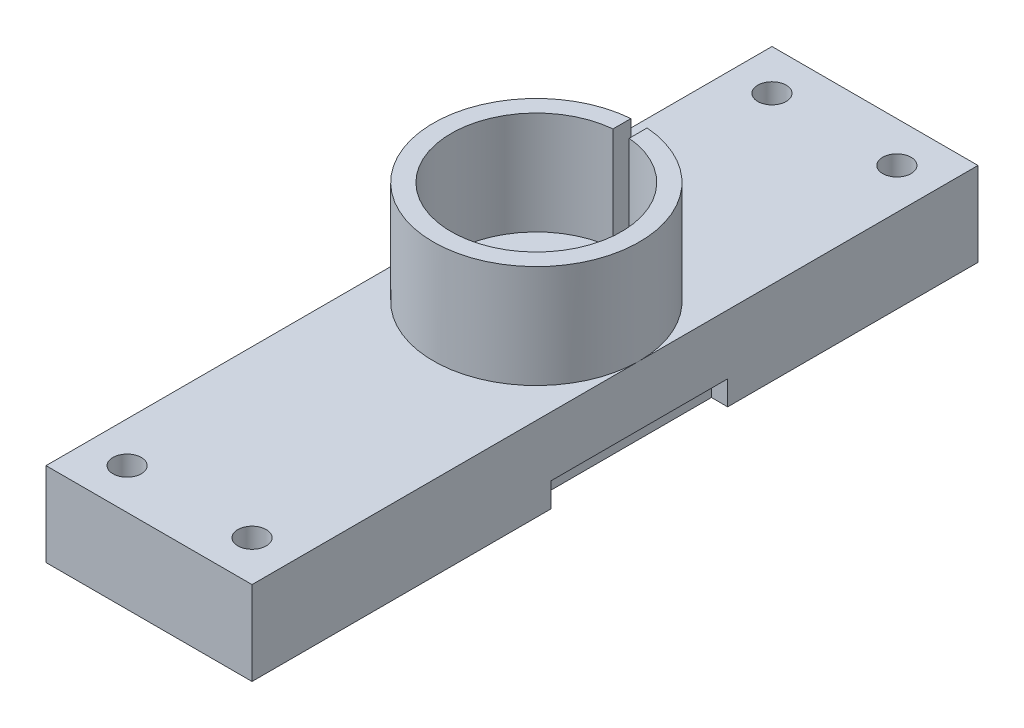
from build123d import *

# Parameters (mm, degrees)
SKETCH1_W           = 25.4
SKETCH1_H           = 89.50000007
SKETCH1_R           = 1.75
BOSS_EXTRUDE1_DEPTH = 10.35
SKETCH2_R           = 12.7
SKETCH2_R_2         = 10.5
BOSS_EXTRUDE2_DEPTH = 12.7
SKETCH5_W           = 2
SKETCH5_H           = 8.007473722
CUT_EXTRUDE1_DEPTH  = 12.7
SKETCH6_R           = 6
CUT_EXTRUDE2_DEPTH  = 3
SKETCH7_R           = 2
CUT_EXTRUDE3_DEPTH  = 7.35
SKETCH8_W           = 21.78000007
SKETCH8_H           = 3
CUT_EXTRUDE4_DEPTH  = 2


with BuildPart() as part:
    # Sketch1 → Boss-Extrude1 (new body)
    with BuildSketch(Plane(origin=(0, 0, 0), x_dir=(1, 0, 0), z_dir=(0, 1, 0))):
        with Locations((12.7, 44.750000035)):
            Rectangle(SKETCH1_W, SKETCH1_H)
        with Locations((5, 84.50000007)):
            Circle(SKETCH1_R, mode=Mode.SUBTRACT)
        with Locations((20.4, 84.50000007)):
            Circle(SKETCH1_R, mode=Mode.SUBTRACT)
        with Locations((5, 5)):
            Circle(SKETCH1_R, mode=Mode.SUBTRACT)
        with Locations((20.4, 5)):
            Circle(SKETCH1_R, mode=Mode.SUBTRACT)
    extrude(amount=BOSS_EXTRUDE1_DEPTH)

    # Sketch2 → Boss-Extrude2 (add)
    with BuildSketch(Plane(origin=(0, 10.35, 0), x_dir=(1, 0, 0), z_dir=(0, 1, 0))):
        with Locations((12.7, 47.75000007)):
            Circle(SKETCH2_R)
        with Locations((12.7, 47.75000007)):
            Circle(SKETCH2_R_2, mode=Mode.SUBTRACT)
    extrude(amount=BOSS_EXTRUDE2_DEPTH)

    # Sketch5 → Cut-Extrude1 (cut)
    with BuildSketch(Plane(origin=(0, 23.05, 0), x_dir=(1, 0, 0), z_dir=(0, 1, 0))):
        with Locations((12.7, 58.700520661)):
            Rectangle(SKETCH5_W, SKETCH5_H)
    extrude(amount=-CUT_EXTRUDE1_DEPTH, mode=Mode.SUBTRACT)

    # Sketch6 → Cut-Extrude2 (cut)
    with BuildSketch(Plane(origin=(0, 10.35, 0), x_dir=(1, 0, 0), z_dir=(0, 1, 0))):
        with Locations((12.7, 47.75000007)):
            Circle(SKETCH6_R)
    extrude(amount=-CUT_EXTRUDE2_DEPTH, mode=Mode.SUBTRACT)

    # Sketch7 → Cut-Extrude3 (cut)
    with BuildSketch(Plane(origin=(0, 7.35, 0), x_dir=(1, 0, 0), z_dir=(0, 1, 0))):
        with Locations((12.7, 47.75000007)):
            Circle(SKETCH7_R)
    extrude(amount=-CUT_EXTRUDE3_DEPTH, mode=Mode.SUBTRACT)

    # Sketch8 → Cut-Extrude4 (cut)
    with BuildSketch(Plane(origin=(25.4, 0, 0), x_dir=(0, 0, -1), z_dir=(1, 0, 0))):
        with Locations((47.750000035, 1.5)):
            Rectangle(SKETCH8_W, SKETCH8_H)
    cut_extrude4 = extrude(amount=-CUT_EXTRUDE4_DEPTH, mode=Mode.SUBTRACT)

    # Mirror1: Cut-Extrude4 across plane
    add(cut_extrude4.mirror(Plane.ZY.offset(-12.7)), mode=Mode.SUBTRACT)


solid = part.part
